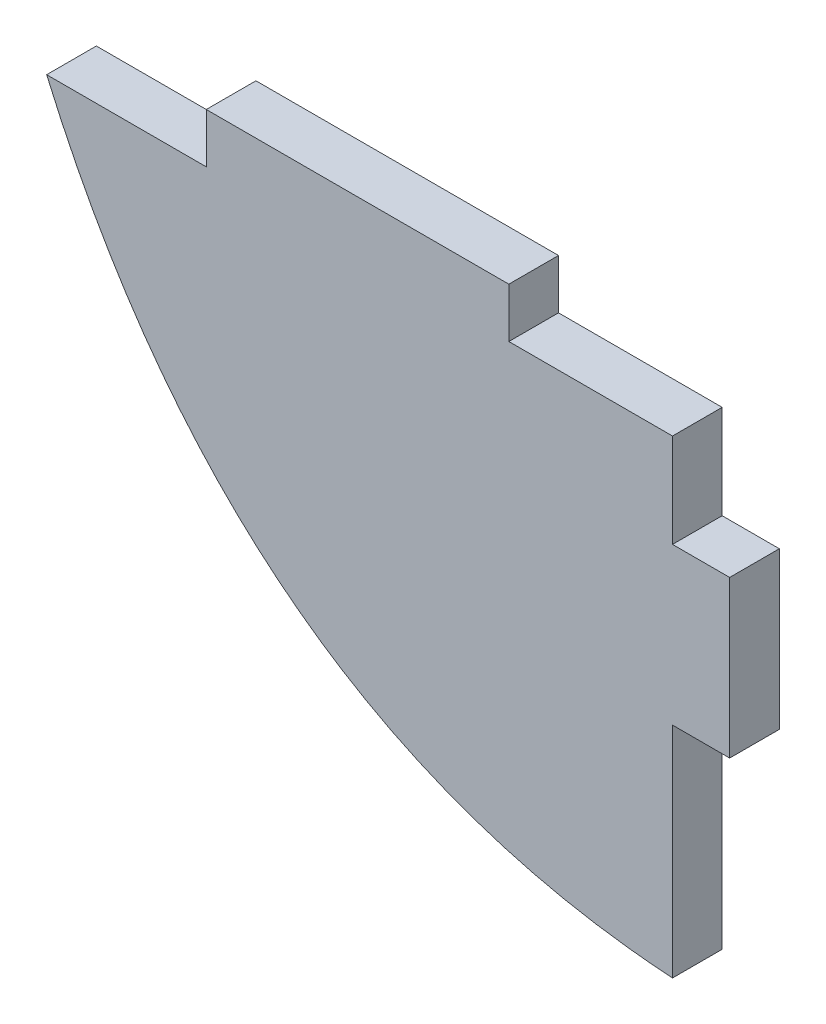
from build123d import *

# Parameters (mm, degrees)
BOSS_EXTRUDE1_DEPTH = 3.175


with BuildPart() as part:
    # Sketch1 → Boss-Extrude1 (new body)
    with BuildSketch(Plane.XY):
        with BuildLine():
            Line((-50.564988155, 9.325788887), (-61.025093708, 9.325788887))
            Line((-61.025093708, 9.325788887), (-61.025093708, 12.500788887))
            Line((-61.025093708, 12.500788887), (-80.363597484, 12.500788887))
            Line((-80.363597484, 12.500788887), (-80.363597484, 9.325788887))
            Line((-80.363597484, 9.325788887), (-90.564988155, 9.325788887))
            add(Edge.make_bspline(
                [(-50.564988155, -20.674211113), (-78.351175561, -18.870925546), (-90.564988155, 9.325788887)],
                knots=[0, 0, 0, 1, 1, 1], degree=2))
            Line((-50.564988155, -20.674211113), (-50.564988155, -6.674211113))
            Line((-50.564988155, -6.674211113), (-46.911258203, -6.674211113))
            Line((-46.911258203, -6.674211113), (-46.911258203, 3.325788887))
            Line((-46.911258203, 3.325788887), (-50.564988155, 3.325788887))
            Line((-50.564988155, 3.325788887), (-50.564988155, 9.325788887))
        make_face()
    extrude(amount=BOSS_EXTRUDE1_DEPTH)


solid = part.part
